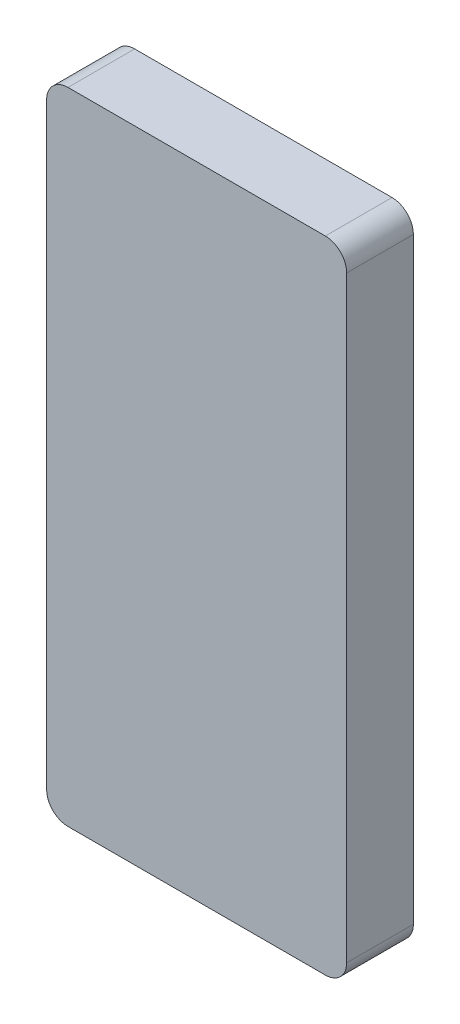
from build123d import *

# Parameters (mm, degrees)
BOSS_EXTRUDE1_DEPTH = 15.875


with BuildPart() as part:
    # Sketch2 → Boss-Extrude1 (new body)
    with BuildSketch(Plane.XY):
        with BuildLine():
            Line((-30.63875, 76.2), (30.63875, 76.2))
            ThreePointArc((30.63875, 76.2), (34.230852448, 74.712102448), (35.71875, 71.12))
            Line((35.71875, 71.12), (35.71875, -71.12))
            ThreePointArc((35.71875, -71.12), (34.230852448, -74.712102448), (30.63875, -76.2))
            Line((30.63875, -76.2), (-30.63875, -76.2))
            ThreePointArc((-30.63875, -76.2), (-34.230852448, -74.712102448), (-35.71875, -71.12))
            Line((-35.71875, -71.12), (-35.71875, 71.12))
            ThreePointArc((-35.71875, 71.12), (-34.230852448, 74.712102448), (-30.63875, 76.2))
        make_face()
    extrude(amount=BOSS_EXTRUDE1_DEPTH)


solid = part.part
